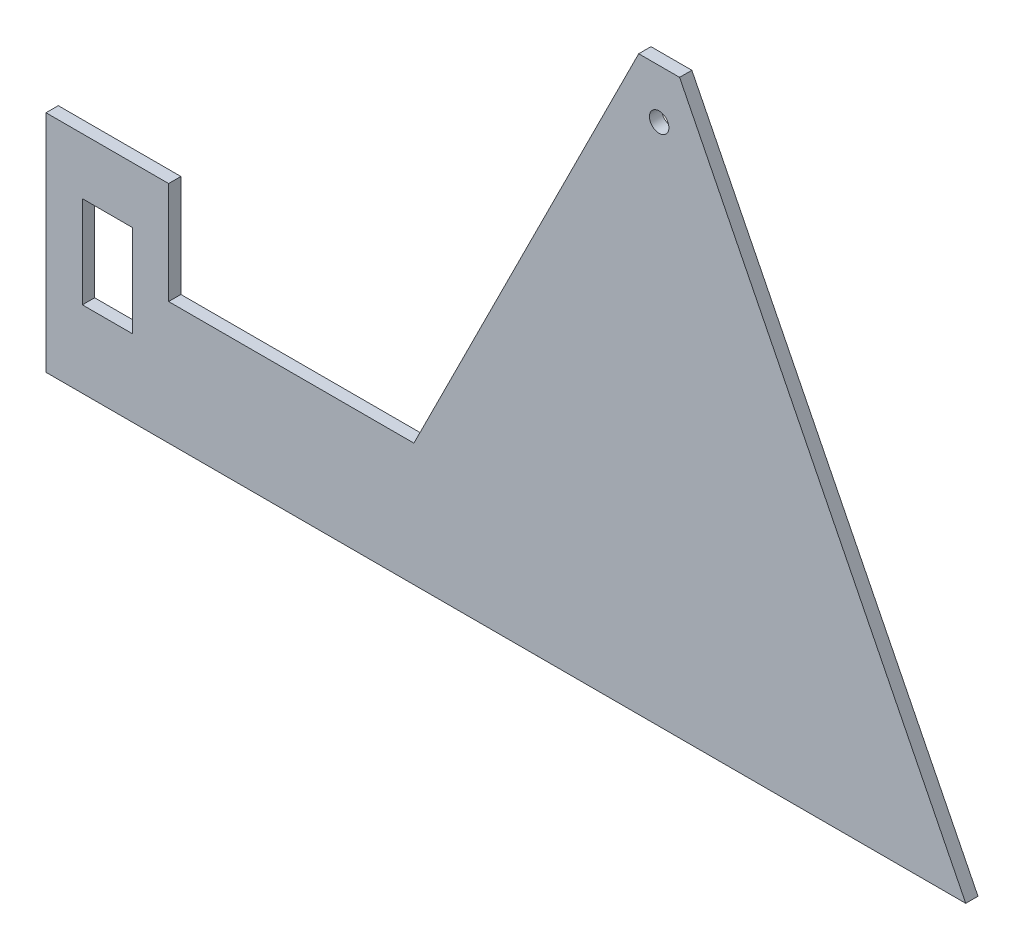
from build123d import *

# Parameters (mm, degrees)
CROQUIS1_W              = 12.2
CROQUIS1_H              = 22.5
SALIENTE_EXTRUIR1_DEPTH = 3
CROQUIS2_R              = 2.38125
CORTAR_EXTRUIR1_DEPTH   = 4


with BuildPart() as part:
    # Croquis1 → Saliente-Extruir1 (new body)
    with BuildSketch(Plane.XY):
        Polygon((75, 0), (-75, 0), (-150, 0), (-150, 30), (-150, 55), (-120, 55), (-120, 30), (-60, 30), (0, 150), align=None)
        with Locations((-135, 30)):
            Rectangle(CROQUIS1_W, CROQUIS1_H, mode=Mode.SUBTRACT)
    extrude(amount=SALIENTE_EXTRUIR1_DEPTH)

    # Croquis2 → Cortar-Extruir1 (cut, through all)
    with BuildSketch(Plane.XY):
        with Locations((0, 128)):
            Circle(CROQUIS2_R)
        Polygon((5, 140), (0, 150), (-5, 140), align=None)
    extrude(amount=CORTAR_EXTRUIR1_DEPTH, mode=Mode.SUBTRACT)


solid = part.part
